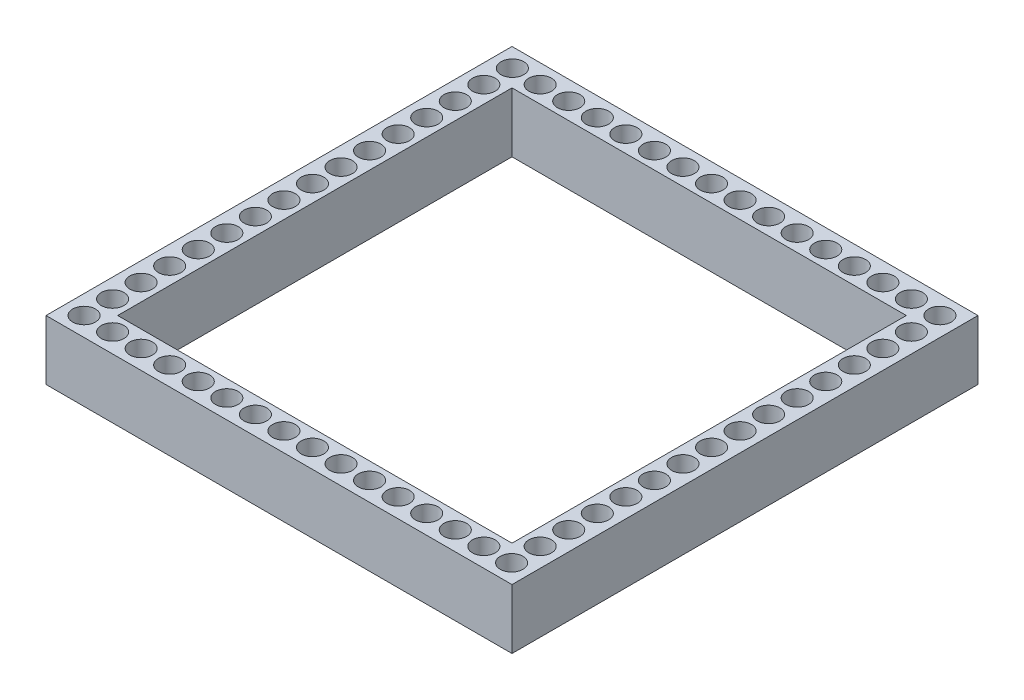
from build123d import *

# Parameters (mm, degrees)
SKETCH2_W           = 39
SKETCH2_H           = 39
SKETCH2_W_2         = 33
SKETCH2_H_2         = 33
BOSS_EXTRUDE1_DEPTH = 5
SKETCH1_R           = 0.95
CUT_EXTRUDE1_DEPTH  = 6


with BuildPart() as part:
    # Sketch2 → Boss-Extrude1 (new body)
    with BuildSketch(Plane(origin=(0, 0, 0), x_dir=(1, 0, 0), z_dir=(0, 1, 0))):
        Rectangle(SKETCH2_W, SKETCH2_H)
        Rectangle(SKETCH2_W_2, SKETCH2_H_2, mode=Mode.SUBTRACT)
    extrude(amount=BOSS_EXTRUDE1_DEPTH)

    # Sketch1 → Cut-Extrude1 (cut, through all)
    with BuildSketch(Plane(origin=(0, 0, 0), x_dir=(1, 0, 0), z_dir=(0, 1, 0))):
        with Locations((-17.909, -17.909)):
            Circle(SKETCH1_R)
        with Locations((-15.519, -17.909)):
            Circle(SKETCH1_R)
        with Locations((-13.129, -17.909)):
            Circle(SKETCH1_R)
        with Locations((-10.739, -17.909)):
            Circle(SKETCH1_R)
        with Locations((-8.349, -17.909)):
            Circle(SKETCH1_R)
        with Locations((-5.959, -17.909)):
            Circle(SKETCH1_R)
        with Locations((-3.569, -17.909)):
            Circle(SKETCH1_R)
        with Locations((-1.179, -17.909)):
            Circle(SKETCH1_R)
        with Locations((1.211, -17.909)):
            Circle(SKETCH1_R)
        with Locations((3.601, -17.909)):
            Circle(SKETCH1_R)
        with Locations((5.991, -17.909)):
            Circle(SKETCH1_R)
        with Locations((8.381, -17.909)):
            Circle(SKETCH1_R)
        with Locations((10.771, -17.909)):
            Circle(SKETCH1_R)
        with Locations((13.161, -17.909)):
            Circle(SKETCH1_R)
        with Locations((15.551, -17.909)):
            Circle(SKETCH1_R)
        with Locations((17.909, 17.909)):
            Circle(SKETCH1_R)
        with Locations((17.909, -17.941)):
            Circle(SKETCH1_R)
        with Locations((17.909, -15.551)):
            Circle(SKETCH1_R)
        with Locations((17.909, -13.161)):
            Circle(SKETCH1_R)
        with Locations((17.909, -10.771)):
            Circle(SKETCH1_R)
        with Locations((17.909, -8.381)):
            Circle(SKETCH1_R)
        with Locations((17.909, -5.991)):
            Circle(SKETCH1_R)
        with Locations((17.909, -3.601)):
            Circle(SKETCH1_R)
        with Locations((17.909, -1.211)):
            Circle(SKETCH1_R)
        with Locations((17.909, 1.179)):
            Circle(SKETCH1_R)
        with Locations((17.909, 3.569)):
            Circle(SKETCH1_R)
        with Locations((17.909, 5.959)):
            Circle(SKETCH1_R)
        with Locations((17.909, 8.349)):
            Circle(SKETCH1_R)
        with Locations((17.909, 10.739)):
            Circle(SKETCH1_R)
        with Locations((17.909, 13.129)):
            Circle(SKETCH1_R)
        with Locations((17.909, 15.519)):
            Circle(SKETCH1_R)
        with Locations((15.519, 17.909)):
            Circle(SKETCH1_R)
        with Locations((13.129, 17.909)):
            Circle(SKETCH1_R)
        with Locations((10.739, 17.909)):
            Circle(SKETCH1_R)
        with Locations((8.349, 17.909)):
            Circle(SKETCH1_R)
        with Locations((5.959, 17.909)):
            Circle(SKETCH1_R)
        with Locations((3.569, 17.909)):
            Circle(SKETCH1_R)
        with Locations((1.179, 17.909)):
            Circle(SKETCH1_R)
        with Locations((-1.211, 17.909)):
            Circle(SKETCH1_R)
        with Locations((-3.601, 17.909)):
            Circle(SKETCH1_R)
        with Locations((-5.991, 17.909)):
            Circle(SKETCH1_R)
        with Locations((-8.381, 17.909)):
            Circle(SKETCH1_R)
        with Locations((-10.771, 17.909)):
            Circle(SKETCH1_R)
        with Locations((-13.161, 17.909)):
            Circle(SKETCH1_R)
        with Locations((-15.551, 17.909)):
            Circle(SKETCH1_R)
        with Locations((-17.909, 17.941)):
            Circle(SKETCH1_R)
        with Locations((-17.909, 15.551)):
            Circle(SKETCH1_R)
        with Locations((-17.909, 13.161)):
            Circle(SKETCH1_R)
        with Locations((-17.909, 10.771)):
            Circle(SKETCH1_R)
        with Locations((-17.909, 8.381)):
            Circle(SKETCH1_R)
        with Locations((-17.909, 5.991)):
            Circle(SKETCH1_R)
        with Locations((-17.909, 3.601)):
            Circle(SKETCH1_R)
        with Locations((-17.909, 1.211)):
            Circle(SKETCH1_R)
        with Locations((-17.909, -1.179)):
            Circle(SKETCH1_R)
        with Locations((-17.909, -3.569)):
            Circle(SKETCH1_R)
        with Locations((-17.909, -5.959)):
            Circle(SKETCH1_R)
        with Locations((-17.909, -8.349)):
            Circle(SKETCH1_R)
        with Locations((-17.909, -10.739)):
            Circle(SKETCH1_R)
        with Locations((-17.909, -13.129)):
            Circle(SKETCH1_R)
        with Locations((-17.909, -15.519)):
            Circle(SKETCH1_R)
    extrude(amount=CUT_EXTRUDE1_DEPTH, mode=Mode.SUBTRACT)


solid = part.part
